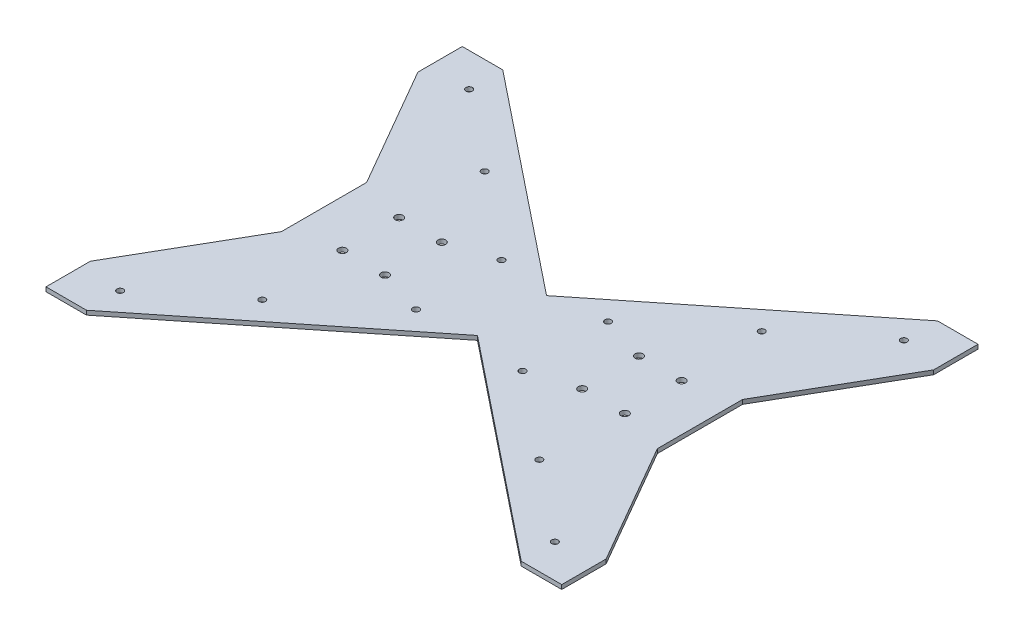
from build123d import *

# Parameters (mm, degrees)
SKETCH1_W               = 365
SKETCH1_H               = 293
BOSS_EXTRUDE1_DEPTH     = 3
CUT_EXTRUDE1_DEPTH      = 4
CUT_EXTRUDE2_DEPTH      = 4
SKETCH8_R               = 2.75
CUT_EXTRUDE3_DEPTH      = 4
MIRROR6_COPY_1_SKETCH_R = 2.75
MIRROR6_COPY_1_DEPTH    = 4
SKETCH9_R               = 2.25
CUT_EXTRUDE4_DEPTH      = 4
MIRROR8_COPY_1_SKETCH_R = 2.25
MIRROR8_COPY_1_DEPTH    = 4
SKETCH10_W              = 1
SKETCH10_H              = 293
CUT_EXTRUDE5_DEPTH      = 4


with BuildPart() as part:
    # Sketch1 → Boss-Extrude1 (new body)
    with BuildSketch(Plane(origin=(0, 0, 0), x_dir=(1, 0, 0), z_dir=(0, 1, 0))):
        Rectangle(SKETCH1_W, SKETCH1_H)
    extrude(amount=BOSS_EXTRUDE1_DEPTH)

    # Sketch3 → Cut-Extrude1 (cut, through all)
    with BuildSketch(Plane(origin=(0, 3, 0), x_dir=(1, 0, 0), z_dir=(0, 1, 0))):
        Polygon((-153, 146.5), (0, 24.3), (153, 146.5), align=None)
    cut_extrude1 = extrude(amount=-CUT_EXTRUDE1_DEPTH, mode=Mode.SUBTRACT)

    # Mirror3: Cut-Extrude1 across plane
    add(cut_extrude1.mirror(Plane.XY), mode=Mode.SUBTRACT)

    # Sketch5 → Cut-Extrude2 (cut, through all)
    with BuildSketch(Plane(origin=(0, 3, 0), x_dir=(1, 0, 0), z_dir=(0, 1, 0))):
        Polygon((-132.307692308, 30), (-182.5, 117), (-182.5, -117), (-132.307692308, -30), align=None)
    cut_extrude2 = extrude(amount=-CUT_EXTRUDE2_DEPTH, mode=Mode.SUBTRACT)

    # Mirror4: Cut-Extrude2 across plane
    add(cut_extrude2.mirror(Plane(origin=(0, 0, 0), x_dir=(0, 0, 1), z_dir=(1, 0, 0))), mode=Mode.SUBTRACT)

    # Sketch8 → Cut-Extrude3 (cut, through all)
    with BuildSketch(Plane(origin=(0, 3, 0), x_dir=(1, 0, 0), z_dir=(0, 1, 0))):
        with Locations(Location((-99.407692308, 20, 0), (0, 0, 270))):  # turned: the seam where the file's is
            Circle(SKETCH8_R)
        with Locations(Location((-69.407692308, 20, 0), (0, 0, 270))):  # turned: the seam where the file's is
            Circle(SKETCH8_R)
    cut_extrude3 = extrude(amount=-CUT_EXTRUDE3_DEPTH, mode=Mode.SUBTRACT)

    # Mirror5: Cut-Extrude3 across plane
    add(cut_extrude3.mirror(Plane.XY), mode=Mode.SUBTRACT)

    # Mirror6: Cut-Extrude3 across plane
    add(cut_extrude3.mirror(Plane(origin=(0, 0, 0), x_dir=(0, 0, 1), z_dir=(1, 0, 0))), mode=Mode.SUBTRACT)

    # Mirror6 copy 1 sketch → Mirror6 copy 1 (cut, through all)
    with BuildSketch(Plane(origin=(0, 3, 0), x_dir=(-1, 0, 0), z_dir=(0, 1, 0))):
        with Locations(Location((-99.407692308, 20, 0), (0, 0, 270))):  # turned: the seam where the file's is
            Circle(MIRROR6_COPY_1_SKETCH_R)
        with Locations(Location((-69.407692308, 20, 0), (0, 0, 270))):  # turned: the seam where the file's is
            Circle(MIRROR6_COPY_1_SKETCH_R)
    extrude(amount=-MIRROR6_COPY_1_DEPTH, mode=Mode.SUBTRACT)

    # Sketch9 → Cut-Extrude4 (cut, through all)
    with BuildSketch(Plane(origin=(0, 3, 0), x_dir=(1, 0, 0), z_dir=(0, 1, 0))):
        with Locations(Location((153, 122.819178082, 0), (0, 0, 270))):  # turned: the seam where the file's is
            Circle(SKETCH9_R)
        with Locations(Location((37.5, 30.102739726, 0), (0, 0, 270))):  # turned: the seam where the file's is
            Circle(SKETCH9_R)
        with Locations(Location((97.5, 78.267123288, 0), (0, 0, 270))):  # turned: the seam where the file's is
            Circle(SKETCH9_R)
    cut_extrude4 = extrude(amount=-CUT_EXTRUDE4_DEPTH, mode=Mode.SUBTRACT)

    # Mirror7: Cut-Extrude4 across plane
    add(cut_extrude4.mirror(Plane(origin=(0, 0, 0), x_dir=(0, 0, 1), z_dir=(1, 0, 0))), mode=Mode.SUBTRACT)

    # Mirror8: Cut-Extrude4 across plane
    add(cut_extrude4.mirror(Plane.XY), mode=Mode.SUBTRACT)

    # Mirror8 copy 1 sketch → Mirror8 copy 1 (cut, through all)
    with BuildSketch(Plane(origin=(0, 3, 0), x_dir=(-1, 0, 0), z_dir=(0, 1, 0))):
        with Locations(Location((153, 122.819178082, 0), (0, 0, 270))):  # turned: the seam where the file's is
            Circle(MIRROR8_COPY_1_SKETCH_R)
        with Locations(Location((37.5, 30.102739726, 0), (0, 0, 270))):  # turned: the seam where the file's is
            Circle(MIRROR8_COPY_1_SKETCH_R)
        with Locations(Location((97.5, 78.267123288, 0), (0, 0, 270))):  # turned: the seam where the file's is
            Circle(MIRROR8_COPY_1_SKETCH_R)
    extrude(amount=-MIRROR8_COPY_1_DEPTH, mode=Mode.SUBTRACT)

    # Sketch10 → Cut-Extrude5 (cut, through all)
    with BuildSketch(Plane(origin=(0, 3, 0), x_dir=(1, 0, 0), z_dir=(0, 1, 0))):
        with Locations((-182, 0)):
            Rectangle(SKETCH10_W, SKETCH10_H)
        with Locations((182, 0)):
            Rectangle(SKETCH10_W, SKETCH10_H)
    extrude(amount=-CUT_EXTRUDE5_DEPTH, mode=Mode.SUBTRACT)


solid = part.part
